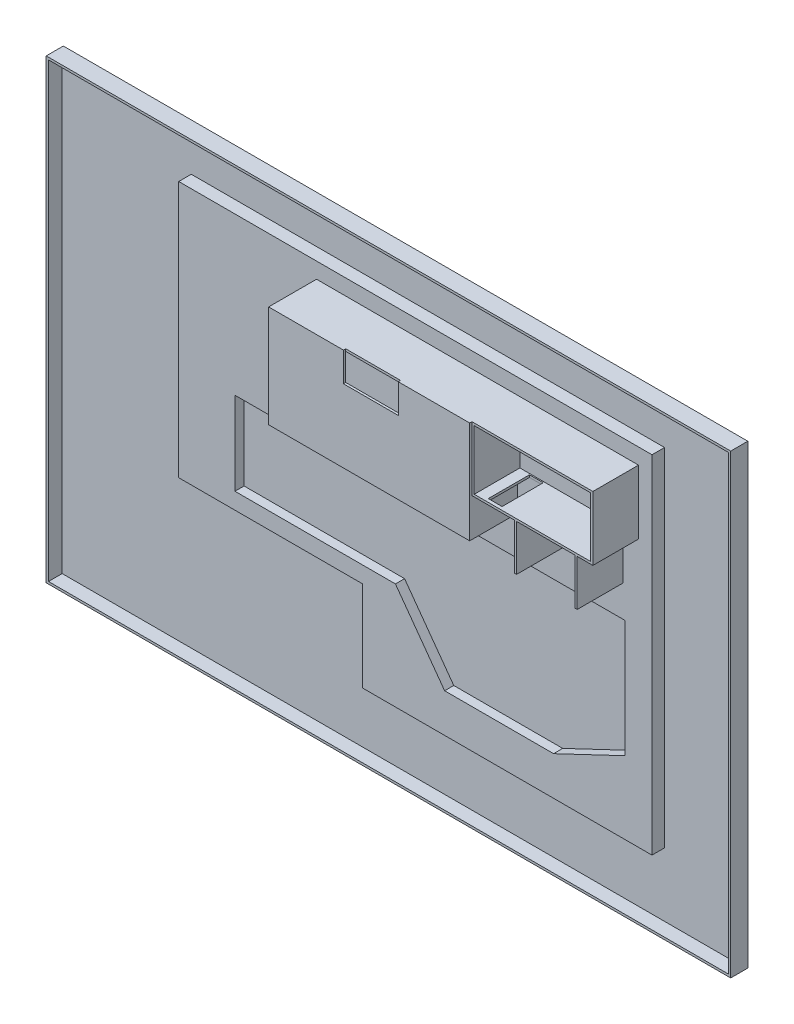
from build123d import *

# Parameters (mm, degrees)
IZIM1_W                     = 60000
IZIM1_H                     = 40000
Y_KSEKLIK_EKSTR_ZYON1_DEPTH = 300
IZIM2_W                     = 60000
IZIM2_H                     = 40000
IZIM2_W_2                   = 59600
IZIM2_H_2                   = 39600
Y_KSEKLIK_EKSTR_ZYON2_DEPTH = 1200
Y_KSEKLIK_EKSTR_ZYON3_DEPTH = 1100
KES_EKSTR_ZYON1_DEPTH       = 800
Y_KSEKLIK_EKSTR_ZYON4_DEPTH = 4000
Y_KSEKLIK_EKSTR_ZYON5_DEPTH = 4000
IZIM8_W                     = 1209.732788708
IZIM8_H                     = 3610.504534554
KES_EKSTR_ZYON2_DEPTH       = 1035
IZIM9_W                     = 17623.002108146
IZIM9_H                     = 8948.600755701
IZIM9_W_2                   = 17223.002108146
IZIM9_H_2                   = 8548.600755701
Y_KSEKLIK_EKSTR_ZYON6_DEPTH = 4000
IZIM10_W                    = 10057.80648616
IZIM10_H                    = 3900
KES_EKSTR_ZYON3_DEPTH       = 1225
IZIM11_W                    = 17623.002108146
IZIM11_H                    = 8948.600755701
Y_KSEKLIK_EKSTR_ZYON7_DEPTH = 200
IZIM12_W                    = 4810.442646605
IZIM12_H                    = 2557.284385886
KES_EKSTR_ZYON4_DEPTH       = 200
IZIM13_R                    = 1235.243034866
KES_EKSTR_ZYON5_DEPTH       = 200


with BuildPart() as part:
    # Çizim1 → Yükseklik-Ekstrüzyon1 (new body)
    with BuildSketch(Plane.XY):
        with Locations((-8635.515452059, -5845.070422535)):
            Rectangle(IZIM1_W, IZIM1_H)
    extrude(amount=Y_KSEKLIK_EKSTR_ZYON1_DEPTH)

    # Çizim2 → Yükseklik-Ekstrüzyon2 (add)
    with BuildSketch(Plane.XY.offset(300)):
        with Locations((-8635.515452059, -5845.070422535)):
            Rectangle(IZIM2_W, IZIM2_H)
        with Locations((-8635.515452059, -5845.070422535)):
            Rectangle(IZIM2_W_2, IZIM2_H_2, mode=Mode.SUBTRACT)
    extrude(amount=Y_KSEKLIK_EKSTR_ZYON2_DEPTH)

    # Çizim4 → Yükseklik-Ekstrüzyon3 (add)
    with BuildSketch(Plane.XY.offset(300)):
        Polygon((-27118.388145752, -12160.051926214), (-27118.388145752, 10327.443184446), (14365.392788981, 10327.443184446), (14365.392788981, -20066.614134071), (-10997.215851809, -20066.614134071), (-10997.215851809, -12160.051926214), align=None)
    extrude(amount=Y_KSEKLIK_EKSTR_ZYON3_DEPTH)

    # Çizim5 → Kes-Ekstrüzyon1 (cut)
    with BuildSketch(Plane.XY.offset(1400)):
        Polygon((-22189.622094101, -3432.028709747), (12003.692389232, -3432.028709747), (12003.692389232, -13700.291317355), (5740.052198591, -16678.087473561), (-3809.432026484, -16678.087473561), (-8122.102321679, -10722.495161149), (-22189.622094101, -10722.495161149), align=None)
    extrude(amount=-KES_EKSTR_ZYON1_DEPTH, mode=Mode.SUBTRACT)

    # Çizim6 → Yükseklik-Ekstrüzyon4 (add)
    with BuildSketch(Plane.XY.offset(1400)):
        Polygon((11813.867998512, -692.882376369), (11813.867998512, 3534.424155195), (6294.884471193, 3534.424155195), (6294.884471193, -692.882376369), (6494.884471193, -692.882376369), (6494.884471193, 3334.424155195), (11613.867998512, 3334.424155195), (11613.867998512, -692.882376369), align=None)
    extrude(amount=Y_KSEKLIK_EKSTR_ZYON4_DEPTH)

    # Çizim7 → Yükseklik-Ekstrüzyon5 (add)
    with BuildSketch(Plane.XY.offset(1400)):
        Polygon((11813.867998512, 3334.424155195), (13183.965395594, 3334.424155195), (13183.965395594, 8948.600755701), (2585.737819961, 8948.600755701), (2585.737819961, 3334.424155195), align=None)
        Polygon((11813.867998512, 3534.424155195), (12983.965395594, 3534.424155195), (12983.965395594, 8748.600755701), (2785.737819961, 8748.600755701), (2785.737819961, 3534.424155195), align=None, mode=Mode.SUBTRACT)
    extrude(amount=Y_KSEKLIK_EKSTR_ZYON5_DEPTH)

    # Çizim8 → Kes-Ekstrüzyon2 (cut)
    with BuildSketch(Plane.XZ.offset(-3334.424155195)):
        with Locations((4330.948838783, 3305.252267277)):
            Rectangle(IZIM8_W, IZIM8_H)
    extrude(amount=-KES_EKSTR_ZYON2_DEPTH, mode=Mode.SUBTRACT)

    # Çizim9 → Yükseklik-Ekstrüzyon6 (add)
    with BuildSketch(Plane.XY.offset(1400)):
        with Locations((-6225.763234112, 4474.30037785)):
            Rectangle(IZIM9_W, IZIM9_H)
        with Locations((-6225.763234112, 4474.30037785)):
            Rectangle(IZIM9_W_2, IZIM9_H_2, mode=Mode.SUBTRACT)
    extrude(amount=Y_KSEKLIK_EKSTR_ZYON6_DEPTH)

    # Çizim10 → Kes-Ekstrüzyon3 (cut)
    with BuildSketch(Plane.XZ):
        with Locations((-9808.361045105, 3450)):
            Rectangle(IZIM10_W, IZIM10_H)
    extrude(amount=-KES_EKSTR_ZYON3_DEPTH, mode=Mode.SUBTRACT)

    # Çizim11 → Yükseklik-Ekstrüzyon7 (add)
    with BuildSketch(Plane.XY.offset(5400)):
        with Locations((-6225.763234112, 4474.30037785)):
            Rectangle(IZIM11_W, IZIM11_H)
    extrude(amount=Y_KSEKLIK_EKSTR_ZYON7_DEPTH)

    # Çizim12 → Kes-Ekstrüzyon4 (cut)
    with BuildSketch(Plane.XY.offset(5600)):
        with Locations((-6077.600034681, 7669.958562758)):
            Rectangle(IZIM12_W, IZIM12_H)
    extrude(amount=-KES_EKSTR_ZYON4_DEPTH, mode=Mode.SUBTRACT)

    # Çizim13 → Kes-Ekstrüzyon5 (cut)
    with BuildSketch(Plane.XZ):
        with Locations((-1310.604150452, 3785.594372986)):
            Circle(IZIM13_R)
    extrude(amount=-KES_EKSTR_ZYON5_DEPTH, mode=Mode.SUBTRACT)


solid = part.part
